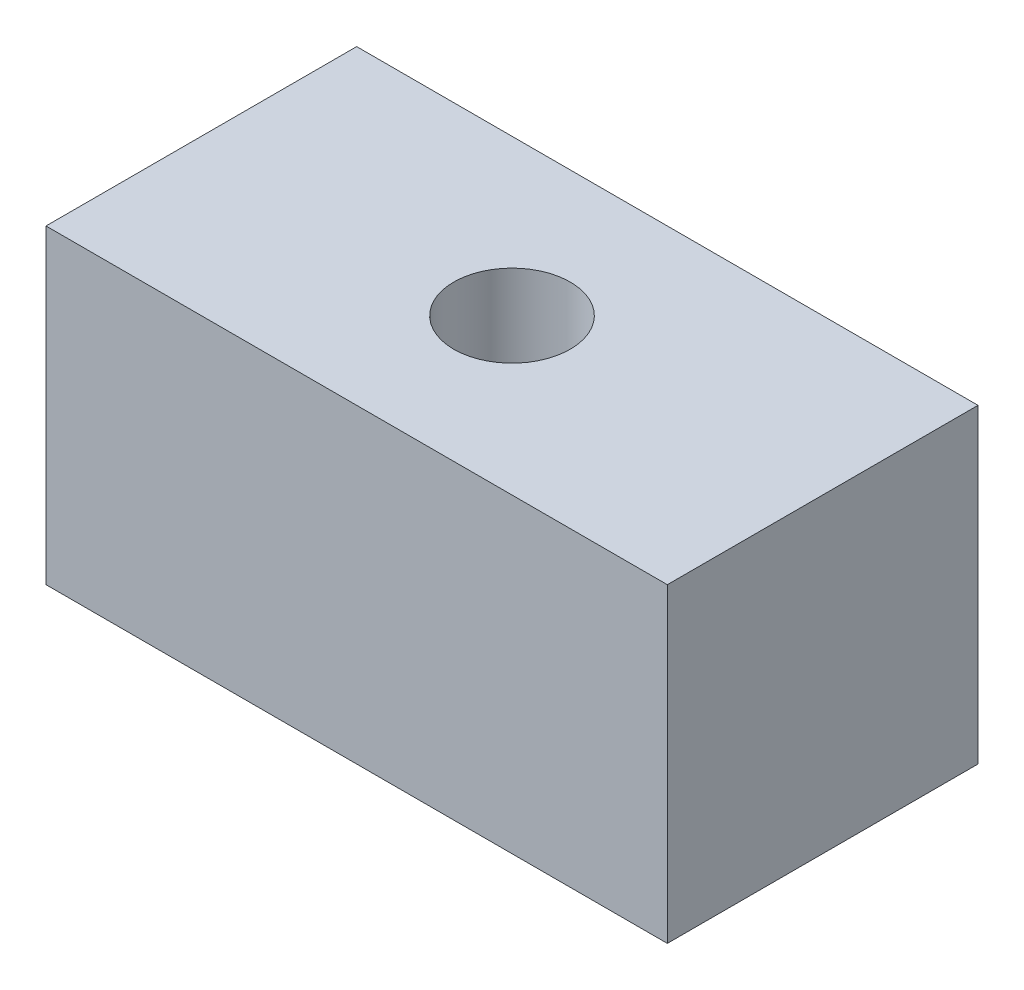
from build123d import *

# Parameters (mm, degrees)
SKETCH3_W           = 101.6
SKETCH3_H           = 50.8
BOSS_EXTRUDE1_DEPTH = 50.8
SKETCH4_R           = 9.525
CUT_EXTRUDE1_DEPTH  = 51.8


with BuildPart() as part:
    # Sketch3 → Boss-Extrude1 (new body)
    with BuildSketch(Plane.XY):
        with Locations((50.8, 25.4)):
            Rectangle(SKETCH3_W, SKETCH3_H)
    extrude(amount=BOSS_EXTRUDE1_DEPTH)

    # Sketch4 → Cut-Extrude1 (cut, through all)
    with BuildSketch(Plane(origin=(0, 50.8, 0), x_dir=(1, 0, 0), z_dir=(0, 1, 0))):
        with Locations((50.8, -25.4)):
            Circle(SKETCH4_R)
    extrude(amount=-CUT_EXTRUDE1_DEPTH, mode=Mode.SUBTRACT)


solid = part.part
